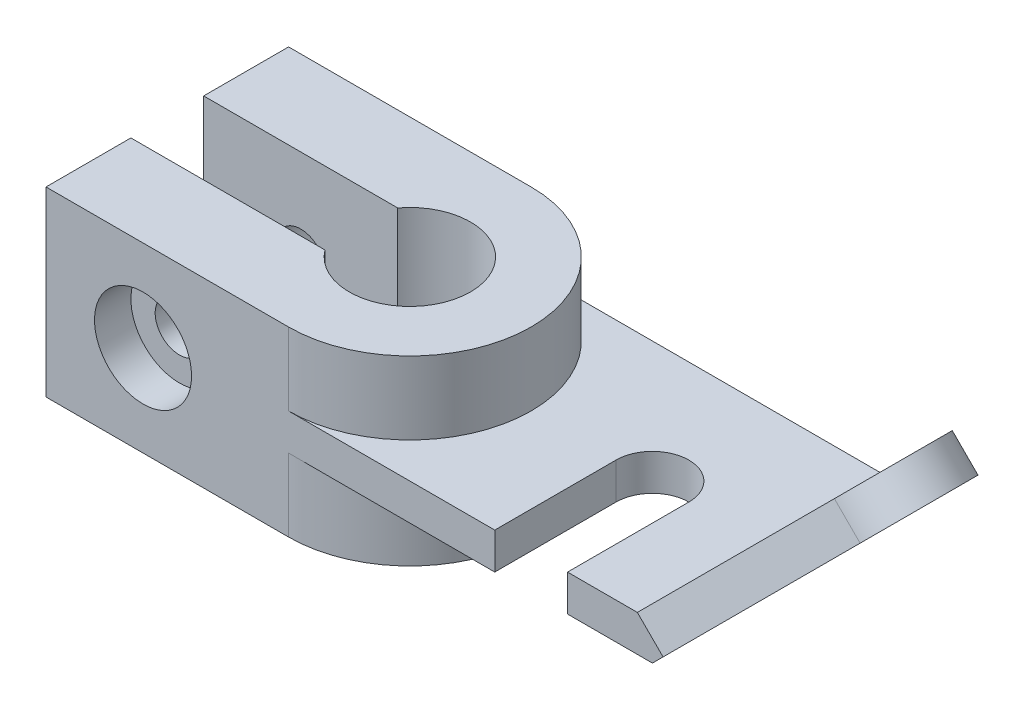
from build123d import *

# Parameters (mm, degrees)
SALIENTE_EXTRUIR1_DEPTH = 45
CROQUIS3_R              = 6
CORTAR_EXTRUIR1_DEPTH   = 61
CROQUIS3_4_R            = 12
CROQUIS3_4_R_2          = 6
CORTAR_EXTRUIR2_DEPTH   = 9
CROQUIS4_R              = 12
CORTAR_EXTRUIR3_DEPTH   = 9
SALIENTE_EXTRUIR3_DEPTH = 45
CORTAR_EXTRUIR4_DEPTH   = 18
CORTAR_EXTRUIR5_DEPTH   = 18
SALIENTE_EXTRUIR4_DEPTH = 45
CROQUIS8_R              = 6
CORTAR_EXTRUIR7_DEPTH   = 61
CROQUIS9_R              = 12
CORTAR_EXTRUIR8_DEPTH   = 9
CROQUIS10_R             = 12
CORTAR_EXTRUIR9_DEPTH   = 9
SALIENTE_EXTRUIR7_DEPTH = 60
CORTAR_EXTRUIR10_DEPTH  = 52.977922061
CORTAR_EXTRUIR11_DEPTH  = 52.977922061
CROQUIS21_R             = 7.5
CORTAR_EXTRUIR13_DEPTH  = 52.977922061


with BuildPart() as part:
    # Croquis2 → Saliente-Extruir1 (new body)
    with BuildSketch(Plane(origin=(0, 0, 0), x_dir=(1, 0, 0), z_dir=(0, 1, 0))):
        with BuildLine():
            Line((-12, 9), (-60, 9))
            Line((-60, 9), (-60, 30))
            Line((-60, 30), (0, 30))
            ThreePointArc((0, 30), (30, 0), (0, -30))
            Line((0, -30), (-60, -30))
            Line((-60, -30), (-60, -9))
            Line((-60, -9), (-12, -9))
            ThreePointArc((-12, -9), (15, 0), (-12, 9))
        make_face()
    extrude(amount=SALIENTE_EXTRUIR1_DEPTH)

    # Croquis3 → Cortar-Extruir1 (cut, through all)
    with BuildSketch(Plane.XY.offset(30)):
        with Locations((-36, 22.5)):
            Circle(CROQUIS3_R)
    extrude(amount=-CORTAR_EXTRUIR1_DEPTH, mode=Mode.SUBTRACT)

    # Croquis3_4 → Cortar-Extruir2 (cut)
    with BuildSketch(Plane.XY.offset(30)):
        with Locations((-36, 22.5)):
            Circle(CROQUIS3_4_R)
        with Locations((-36, 22.5)):
            Circle(CROQUIS3_4_R_2, mode=Mode.SUBTRACT)
    extrude(amount=-CORTAR_EXTRUIR2_DEPTH, mode=Mode.SUBTRACT)

    # Croquis4 → Cortar-Extruir3 (cut)
    with BuildSketch(Plane(origin=(0, 0, -30), x_dir=(-1, 0, 0), z_dir=(0, 0, -1))):
        with Locations((36, 22.5)):
            Circle(CROQUIS4_R)
    extrude(amount=-CORTAR_EXTRUIR3_DEPTH, mode=Mode.SUBTRACT)

    # Croquis5 → Saliente-Extruir3 (add, through all)
    with BuildSketch(Plane(origin=(0, 45, 0), x_dir=(1, 0, 0), z_dir=(0, 1, 0))):
        with BuildLine():
            Line((51, 0), (51, -30))
            Line((51, -30), (0, -30))
            ThreePointArc((0, -30), (30, 0), (0, 30))
            Line((0, 30), (90, 30))
            Line((90, 30), (90, -30))
            Line((90, -30), (69, -30))
            Line((69, -30), (69, 0))
            ThreePointArc((69, 0), (60, 9), (51, 0))
        make_face()
    extrude(amount=-SALIENTE_EXTRUIR3_DEPTH)

    # Croquis6 → Cortar-Extruir4 (cut)
    with BuildSketch(Plane(origin=(0, 45, 0), x_dir=(1, 0, 0), z_dir=(0, 1, 0))):
        with BuildLine():
            Line((69, -30), (90, -30))
            Line((90, -30), (90, 30))
            Line((90, 30), (0, 30))
            Line((0, 30), (0, 15))
            ThreePointArc((0, 15), (15, 0), (0, -15))
            Line((0, -15), (0, -30))
            Line((0, -30), (51, -30))
            Line((51, -30), (51, 0))
            ThreePointArc((51, 0), (60, 9), (69, 0))
            Line((69, 0), (69, -30))
        make_face()
    extrude(amount=-CORTAR_EXTRUIR4_DEPTH, mode=Mode.SUBTRACT)

    # Croquis7 → Cortar-Extruir5 (cut)
    with BuildSketch(Plane.XZ):
        with BuildLine():
            Line((51, 30), (51, 0))
            ThreePointArc((51, 0), (60, -9), (69, 0))
            Line((69, 0), (69, 30))
            Line((69, 30), (90, 30))
            Line((90, 30), (90, -30))
            Line((90, -30), (0, -30))
            Line((0, -30), (0, -15))
            ThreePointArc((0, -15), (15, 0), (0, 15))
            Line((0, 15), (0, 30))
            Line((0, 30), (51, 30))
        make_face()
    extrude(amount=-CORTAR_EXTRUIR5_DEPTH, mode=Mode.SUBTRACT)

    # Croquis2_3 → Saliente-Extruir4 (add)
    with BuildSketch(Plane(origin=(0, 0, 0), x_dir=(1, 0, 0), z_dir=(0, 1, 0))):
        with BuildLine():
            Line((-12, 9), (-60, 9))
            Line((-60, 9), (-60, 30))
            Line((-60, 30), (0, 30))
            ThreePointArc((0, 30), (30, 0), (0, -30))
            Line((0, -30), (-60, -30))
            Line((-60, -30), (-60, -9))
            Line((-60, -9), (-12, -9))
            ThreePointArc((-12, -9), (15, 0), (-12, 9))
        make_face()
    extrude(amount=SALIENTE_EXTRUIR4_DEPTH)

    # Croquis8 → Cortar-Extruir7 (cut, through all)
    with BuildSketch(Plane.XY.offset(30)):
        with Locations((-36, 22.5)):
            Circle(CROQUIS8_R)
    extrude(amount=-CORTAR_EXTRUIR7_DEPTH, mode=Mode.SUBTRACT)

    # Croquis9 → Cortar-Extruir8 (cut)
    with BuildSketch(Plane.XY.offset(30)):
        with Locations((-36, 22.5)):
            Circle(CROQUIS9_R)
    extrude(amount=-CORTAR_EXTRUIR8_DEPTH, mode=Mode.SUBTRACT)

    # Croquis10 → Cortar-Extruir9 (cut)
    with BuildSketch(Plane(origin=(0, 0, -30), x_dir=(-1, 0, 0), z_dir=(0, 0, -1))):
        with Locations((36, 22.5)):
            Circle(CROQUIS10_R)
    extrude(amount=-CORTAR_EXTRUIR9_DEPTH, mode=Mode.SUBTRACT)

    # Croquis16 → Saliente-Extruir7 (add, through all)
    with BuildSketch(Plane.XY.offset(30)):
        Polygon((90, 18), (132.779960262, 60.779960262), (126.415999231, 67.143921292), (83.636038969, 24.363961031), align=None)
    extrude(amount=-SALIENTE_EXTRUIR7_DEPTH)

    # Croquis18 → Cortar-Extruir10 (cut, through all)
    with BuildSketch(Plane(origin=(29.636038969, -29.636038969, 0), x_dir=(0, 0, 1), z_dir=(-0.707106781, 0.707106781, 0))):
        with BuildLine():
            Line((-30, 136.867532368), (-30, 80.09545443))
            Line((-30, 80.09545443), (-14.205841491, 126.68355433))
            ThreePointArc((-14.205841491, 126.68355433), (-8.739555783, 134.058519396), (0, 136.867532368))
            Line((0, 136.867532368), (-30, 136.867532368))
        make_face()
    extrude(amount=-CORTAR_EXTRUIR10_DEPTH, mode=Mode.SUBTRACT)

    # Croquis19 → Cortar-Extruir11 (cut, through all)
    with BuildSketch(Plane(origin=(29.636038969, -29.636038969, 0), x_dir=(0, 0, 1), z_dir=(-0.707106781, 0.707106781, 0))):
        with BuildLine():
            Line((30, 80.09545443), (14.205841491, 126.68355433))
            ThreePointArc((14.205841491, 126.68355433), (8.739555783, 134.058519396), (0, 136.867532368))
            Line((0, 136.867532368), (30, 136.867532368))
            Line((30, 136.867532368), (30, 80.09545443))
        make_face()
    extrude(amount=-CORTAR_EXTRUIR11_DEPTH, mode=Mode.SUBTRACT)

    # Croquis21 → Cortar-Extruir13 (cut, through all)
    with BuildSketch(Plane(origin=(29.636038969, -29.636038969, 0), x_dir=(0, 0, 1), z_dir=(-0.707106781, 0.707106781, 0))):
        with Locations((0, 121.867532368)):
            Circle(CROQUIS21_R)
    extrude(amount=-CORTAR_EXTRUIR13_DEPTH, mode=Mode.SUBTRACT)


solid = part.part
